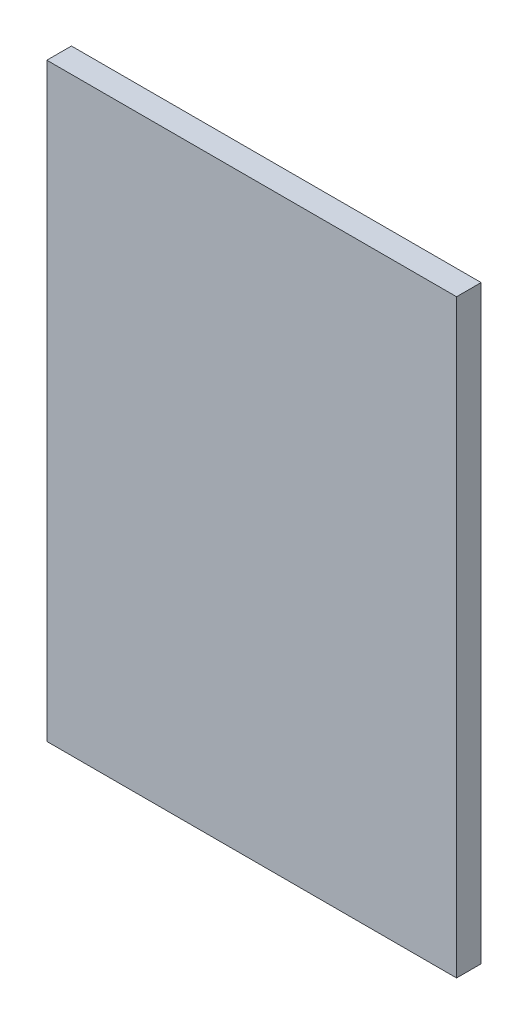
from build123d import *

# Parameters (mm, degrees)
SKETCH_1_W      = 50
SKETCH_1_H      = 72
EXTRUDE_1_DEPTH = 3


with BuildPart() as part:
    # 草图1 → 凸台-拉伸1 (new body)
    with BuildSketch(Plane.XY):
        with Locations((18.648373984, -28.479674797)):
            Rectangle(SKETCH_1_W, SKETCH_1_H)
    extrude(amount=EXTRUDE_1_DEPTH)


solid = part.part
